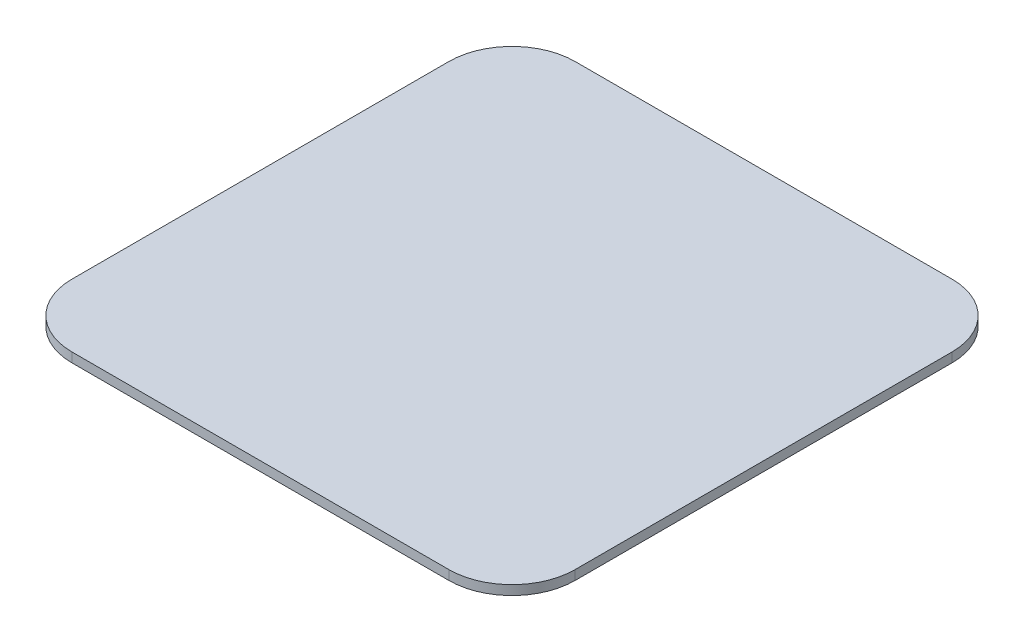
from build123d import *

# Parameters (mm, degrees)
SKETCH_1_W      = 159.5
SKETCH_1_H      = 159.5
EXTRUDE_1_DEPTH = 3
FILLET_1_R      = 20


with BuildPart() as part:
    # 草图1 → 凸台-拉伸1 (new body)
    with BuildSketch(Plane(origin=(0, 0, 0), x_dir=(1, 0, 0), z_dir=(0, 1, 0))):
        Rectangle(SKETCH_1_W, SKETCH_1_H)
    extrude(amount=EXTRUDE_1_DEPTH)

    # 圆角1
    fillet_1_edges = [part.edges().sort_by_distance(p)[0] for p in [
        (-79.75, 1.5, -79.75),
        (79.75, 1.5, -79.75),
        (79.75, 1.5, 79.75),
        (-79.75, 1.5, 79.75),
    ]]
    fillet(fillet_1_edges, radius=FILLET_1_R)


solid = part.part
